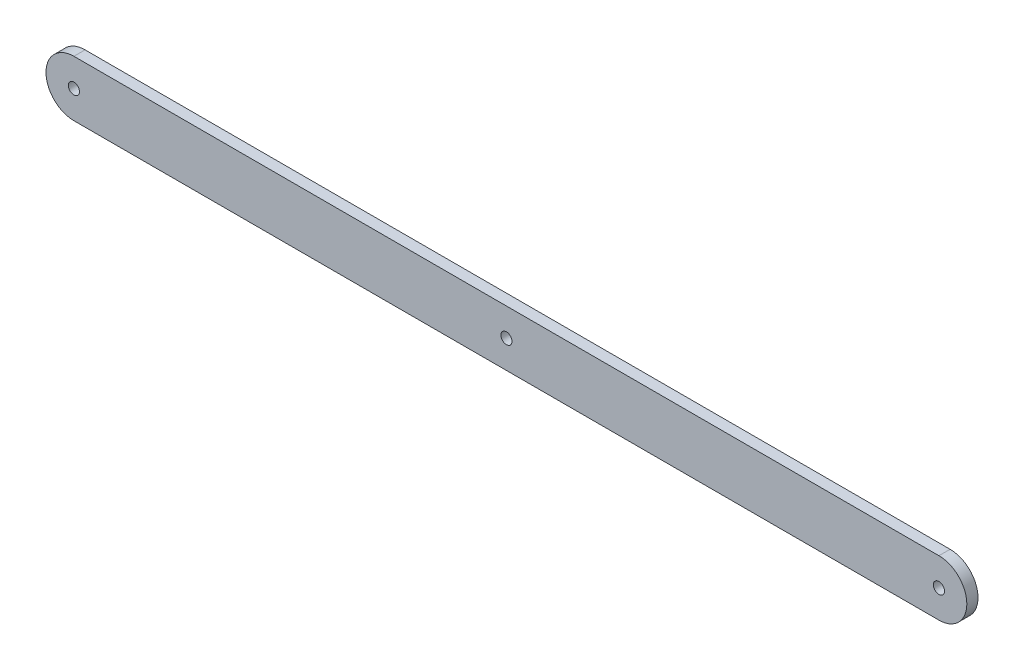
from build123d import *

# Parameters (mm, degrees)
SKETCH_1_R      = 2
EXTRUDE_1_DEPTH = 4


with BuildPart() as part:
    # 草图1 → 凸台-拉伸1 (new body)
    with BuildSketch(Plane.XY):
        with BuildLine():
            Line((-102.380952381, 17.976190476), (207.619047619, 17.976190476))
            ThreePointArc((207.619047619, 17.976190476), (217.619047619, 27.976190476), (207.619047619, 37.976190476))
            Line((207.619047619, 37.976190476), (-102.380952381, 37.976190476))
            ThreePointArc((-102.380952381, 37.976190476), (-112.380952381, 27.976190476), (-102.380952381, 17.976190476))
        make_face()
        with Locations((207.619047619, 27.976190476)):
            Circle(SKETCH_1_R, mode=Mode.SUBTRACT)
        with Locations((52.619047619, 27.976190476)):
            Circle(SKETCH_1_R, mode=Mode.SUBTRACT)
        with Locations((-102.380952381, 27.976190476)):
            Circle(SKETCH_1_R, mode=Mode.SUBTRACT)
    extrude(amount=EXTRUDE_1_DEPTH)


solid = part.part
